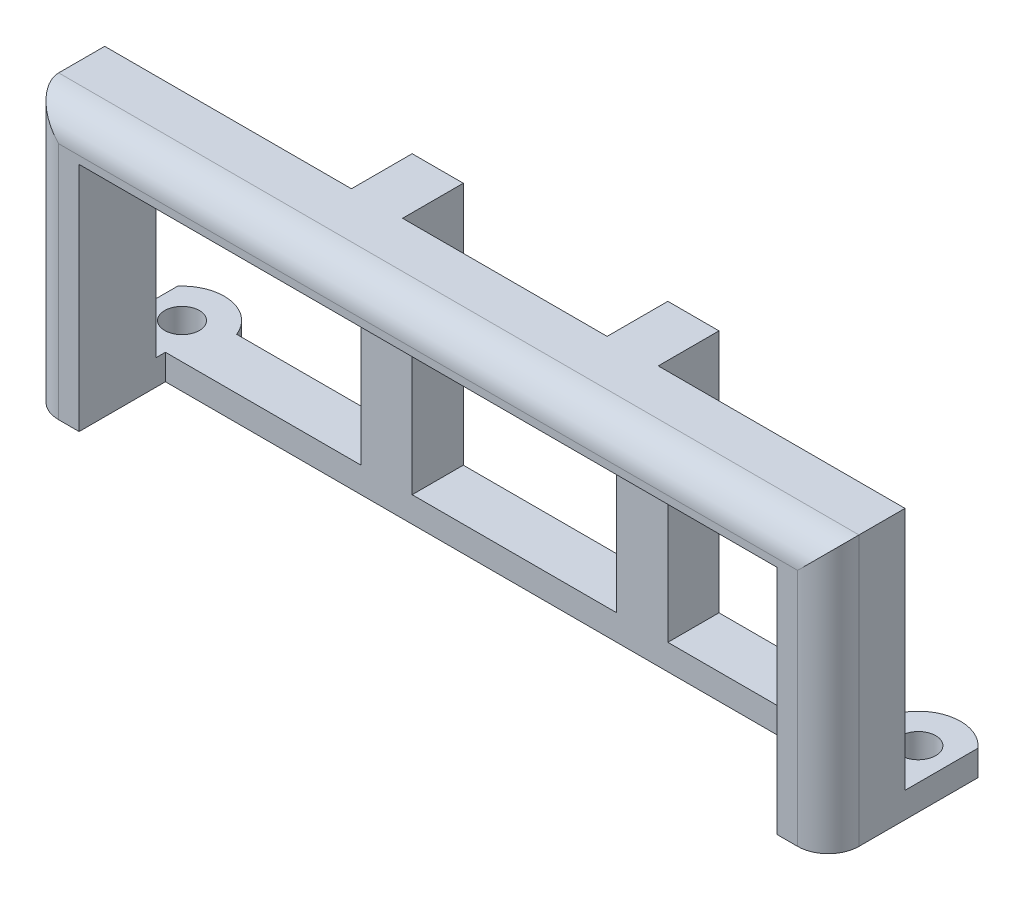
from build123d import *

# Parameters (mm, degrees)
BOSS_EXTRUDE1_DEPTH = 4.7625
SKETCH1_3_W         = 6.35
SKETCH1_3_H         = 9.525
SKETCH1_3_H_2       = 6.35
BOSS_EXTRUDE2_DEPTH = 28.73375
SKETCH2_W           = 12.7
SKETCH2_H           = 6.35
SKETCH2_R           = 2.15265
BOSS_EXTRUDE3_DEPTH = 3.175
FILLET11_R          = 3.81


with BuildPart() as part:
    # Sketch1 → Boss-Extrude1 (new body)
    with BuildSketch(Plane(origin=(0, 0, 0), x_dir=(1, 0, 0), z_dir=(0, 1, 0))):
        Polygon((-49.68875, 4.7625), (-49.68875, -4.7625), (49.68875, -4.7625), (49.68875, 4.7625), (-12.7, 4.7625), (-12.7, 12.303125), (-19.05, 12.303125), (-19.05, 4.7625), align=None)
    extrude(amount=BOSS_EXTRUDE1_DEPTH)

    # Sketch1_3 → Boss-Extrude2 (add)
    with BuildSketch(Plane(origin=(0, 0, 0), x_dir=(1, 0, 0), z_dir=(0, 1, 0))):
        with Locations((-46.51375, 0)):
            Rectangle(SKETCH1_3_W, SKETCH1_3_H)
        with Locations((46.51375, 0)):
            Rectangle(SKETCH1_3_W, SKETCH1_3_H)
        with Locations((-15.875, 9.128125)):
            Rectangle(SKETCH1_3_W, SKETCH1_3_H_2)
    extrude(amount=-BOSS_EXTRUDE2_DEPTH)

    # Mirror1: part across plane


with BuildPart() as part_1:
    add(part.part)
    add(part.part.mirror(Plane(origin=(0, 0, 0), x_dir=(0, 0, 1), z_dir=(1, 0, 0))))

    # Sketch2 → Boss-Extrude3 (add)
    # profile 1 of 2: a face of its own
    with BuildSketch(Plane.XZ.offset(28.73375)):
        with Locations((-6.35, -9.128125)):
            Rectangle(SKETCH2_W, SKETCH2_H)
    # profile 2 of 2: a face of its own
    with BuildSketch(Plane.XZ.offset(28.73375)):
        with BuildLine():
            Line((-49.68875, 4.7625), (-49.68875, -13.814359467))
            ThreePointArc((-49.68875, -13.814359467), (-44.838220371, -15.559917245), (-40.842233144, -12.303125))
            Line((-40.842233144, -12.303125), (-15.875, -12.303125))
            Line((-15.875, -12.303125), (-15.875, -5.953125))
            Line((-15.875, -5.953125), (-43.33875, -5.953125))
            Line((-43.33875, -5.953125), (-43.33875, 4.7625))
            Line((-43.33875, 4.7625), (-49.68875, 4.7625))
        make_face()
        with Locations((-45.72, -10.398125)):
            Circle(SKETCH2_R, mode=Mode.SUBTRACT)
    boss_extrude3 = extrude(amount=-BOSS_EXTRUDE3_DEPTH)

    # Mirror3: Boss-Extrude3 across plane
    add(boss_extrude3.mirror(Plane(origin=(0, 0, 0), x_dir=(0, 0, 1), z_dir=(1, 0, 0))))

    # Fillet11
    fillet11_edges = [part_1.edges().sort_by_distance(p)[0] for p in [
        (49.68875, -11.985625, 4.7625),
        (-49.68875, -11.985625, 4.7625),
        (0, 4.7625, 4.7625),
    ]]
    fillet(fillet11_edges, radius=FILLET11_R)


solid = part_1.part
